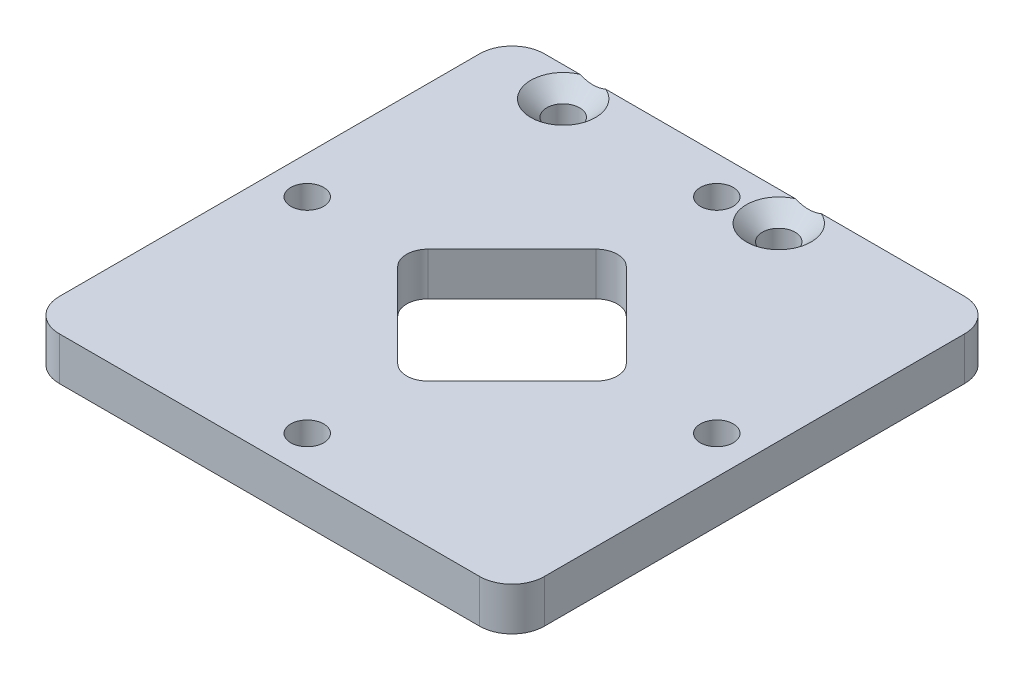
from build123d import *

# Parameters (mm, degrees)
SKETCH_1_W                = 45
SKETCH_1_H                = 45
EXTRUDE_1_DEPTH           = 4
SKETCH_2_R                = 1.525
CUT_EXTRUDE_1_DEPTH       = 4
FILLET_1_R                = 3
HOLE_WIZARD_1_D           = 3
HOLE_WIZARD_1_CSINK_D     = 6
HOLE_WIZARD_1_CSINK_ANGLE = 90
SKETCH_5_R                = 1.525
CUT_EXTRUDE_2_DEPTH       = 10
HOLE_WIZARD_2_D           = 3
HOLE_WIZARD_2_CSINK_D     = 6
HOLE_WIZARD_2_CSINK_ANGLE = 90
CUT_EXTRUDE_3_DEPTH       = 1
CUT_EXTRUDE_3_DEPTH_BACK  = 5
FILLET_2_R                = 2
SKETCH_3_R                = 1.525
CUT_EXTRUDE_4_DEPTH       = 1
CUT_EXTRUDE_4_DEPTH_BACK  = 5


with BuildPart() as part:
    # 草图1 → 凸台-拉伸1 (new body)
    with BuildSketch(Plane(origin=(0, 0, 0), x_dir=(1, 0, 0), z_dir=(0, 1, 0))):
        Rectangle(SKETCH_1_W, SKETCH_1_H)
    extrude(amount=EXTRUDE_1_DEPTH)

    # 草图2 → 切除-拉伸1 (cut)
    with BuildSketch(Plane(origin=(0, 4, 0), x_dir=(1, 0, 0), z_dir=(0, 1, 0))):
        with Locations((-19, 0)):
            Circle(SKETCH_2_R)
        with Locations((19, 0)):
            Circle(SKETCH_2_R)
    extrude(amount=-CUT_EXTRUDE_1_DEPTH, mode=Mode.SUBTRACT)

    # 圆角1
    fillet_1_edges = [part.edges().sort_by_distance(p)[0] for p in [
        (22.5, 2, 22.5),
        (-22.5, 2, 22.5),
        (-22.5, 2, -22.5),
        (22.5, 2, -22.5),
    ]]
    fillet(fillet_1_edges, radius=FILLET_1_R)

    # 孔1 (through all)
    with Locations(Plane(origin=(-15, 4, -19.75), x_dir=(0, 0, 1), z_dir=(0, 1, 0))):
        with Locations((0, 0), (0, 20)):
            CounterSinkHole(HOLE_WIZARD_1_D / 2, HOLE_WIZARD_1_CSINK_D / 2, counter_sink_angle=HOLE_WIZARD_1_CSINK_ANGLE)

    # 草图5 → 切除-拉伸2 (cut)
    with BuildSketch(Plane(origin=(0, 4, 0), x_dir=(1, 0, 0), z_dir=(0, 1, 0))):
        with Locations((0, 19)):
            Circle(SKETCH_5_R)
        with Locations((0, -19)):
            Circle(SKETCH_5_R)
    extrude(amount=-CUT_EXTRUDE_2_DEPTH, mode=Mode.SUBTRACT)

    # 孔2 (through all)
    with Locations(Plane(origin=(0, 0, 0), x_dir=(-1, 0, 0), z_dir=(0, -1, 0))):
        with Locations((0, 19)):
            CounterSinkHole(HOLE_WIZARD_2_D / 2, HOLE_WIZARD_2_CSINK_D / 2, counter_sink_angle=HOLE_WIZARD_2_CSINK_ANGLE)

    # 草图8 → 切除-拉伸3 (cut, two sides)
    with BuildSketch(Plane(origin=(0, 4, 0), x_dir=(1, 0, 0), z_dir=(0, 1, 0))) as cut_extrude_3_sk:
        Polygon((0, 10.606601718), (-10.606601718, 0), (0, -10.606601718), (10.606601718, 0), align=None)
    extrude(amount=CUT_EXTRUDE_3_DEPTH, mode=Mode.SUBTRACT)
    extrude(cut_extrude_3_sk.sketch, amount=-CUT_EXTRUDE_3_DEPTH_BACK, mode=Mode.SUBTRACT)

    # 圆角2
    fillet_2_edges = [part.edges().sort_by_distance(p)[0] for p in [
        (0, 2, -10.606601718),
        (10.606601718, 2, 0),
        (0, 2, 10.606601718),
        (-10.606601718, 2, 0),
    ]]
    fillet(fillet_2_edges, radius=FILLET_2_R)

    # 草图3 → 切除-拉伸4 (cut, two sides)
    with BuildSketch(Plane(origin=(0, 4, 0), x_dir=(1, 0, 0), z_dir=(0, 1, 0))) as cut_extrude_4_sk:
        with Locations((5, 19.75)):
            Circle(SKETCH_3_R)
        with Locations((-15, 19.75)):
            Circle(SKETCH_3_R)
    extrude(amount=CUT_EXTRUDE_4_DEPTH, mode=Mode.SUBTRACT)
    extrude(cut_extrude_4_sk.sketch, amount=-CUT_EXTRUDE_4_DEPTH_BACK, mode=Mode.SUBTRACT)


solid = part.part
